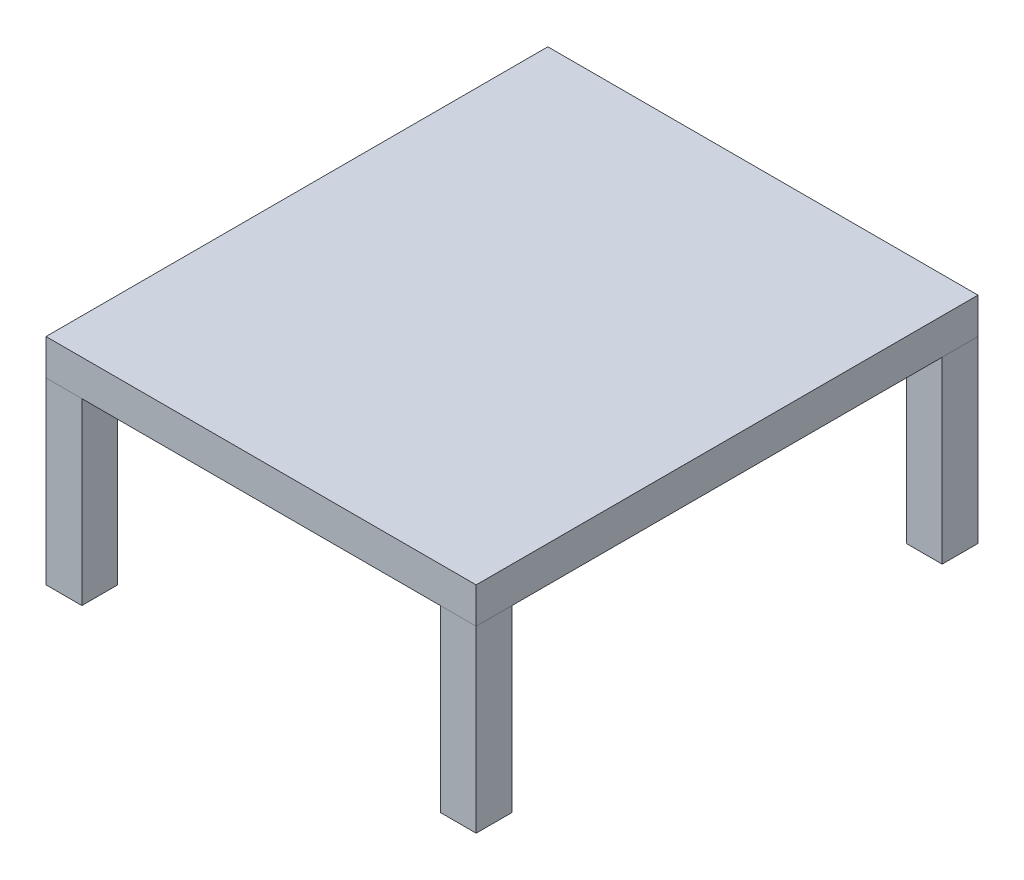
from build123d import *

# Parameters (mm, degrees)
SKETCH1_W             = 50.8
SKETCH1_H             = 50.8
BOSS_EXTRUDE1_DEPTH   = 254
BOSS_EXTRUDE1_2_DEPTH = 254
SKETCH2_W             = 609.6
SKETCH2_H             = 711.2
BOSS_EXTRUDE2_DEPTH   = 50.8


with BuildPart() as part:
    # Sketch1 → Boss-Extrude1 (new body)
    with BuildSketch(Plane(origin=(0, 0, 0), x_dir=(1, 0, 0), z_dir=(0, 1, 0))):
        with Locations((-279.4, 330.2)):
            Rectangle(SKETCH1_W, SKETCH1_H)
    extrude(amount=BOSS_EXTRUDE1_DEPTH)


with BuildPart() as body_2:
    # Sketch1 → Boss-Extrude1 2 (new body)
    with BuildSketch(Plane(origin=(0, 0, 0), x_dir=(1, 0, 0), z_dir=(0, 1, 0))):
        with Locations((-279.4, -330.2)):
            Rectangle(SKETCH1_W, SKETCH1_H)
    extrude(amount=BOSS_EXTRUDE1_2_DEPTH)


with BuildPart() as body_3:
    # Mirror4: mirrored copy
    add(part.part.mirror(Plane(origin=(0, 0, 0), x_dir=(0, 0, 1), z_dir=(1, 0, 0))))


with BuildPart() as body_4:
    # Mirror4 2: mirrored copy
    add(body_2.part.mirror(Plane(origin=(0, 0, 0), x_dir=(0, 0, 1), z_dir=(1, 0, 0))))


with BuildPart() as body_5:
    # Sketch2 → Boss-Extrude2 (new body)
    with BuildSketch(Plane(origin=(0, 254, 0), x_dir=(1, 0, 0), z_dir=(0, 1, 0))):
        Rectangle(SKETCH2_W, SKETCH2_H)
    extrude(amount=BOSS_EXTRUDE2_DEPTH)


solid = Compound([part.part, body_2.part, body_3.part, body_4.part, body_5.part])
